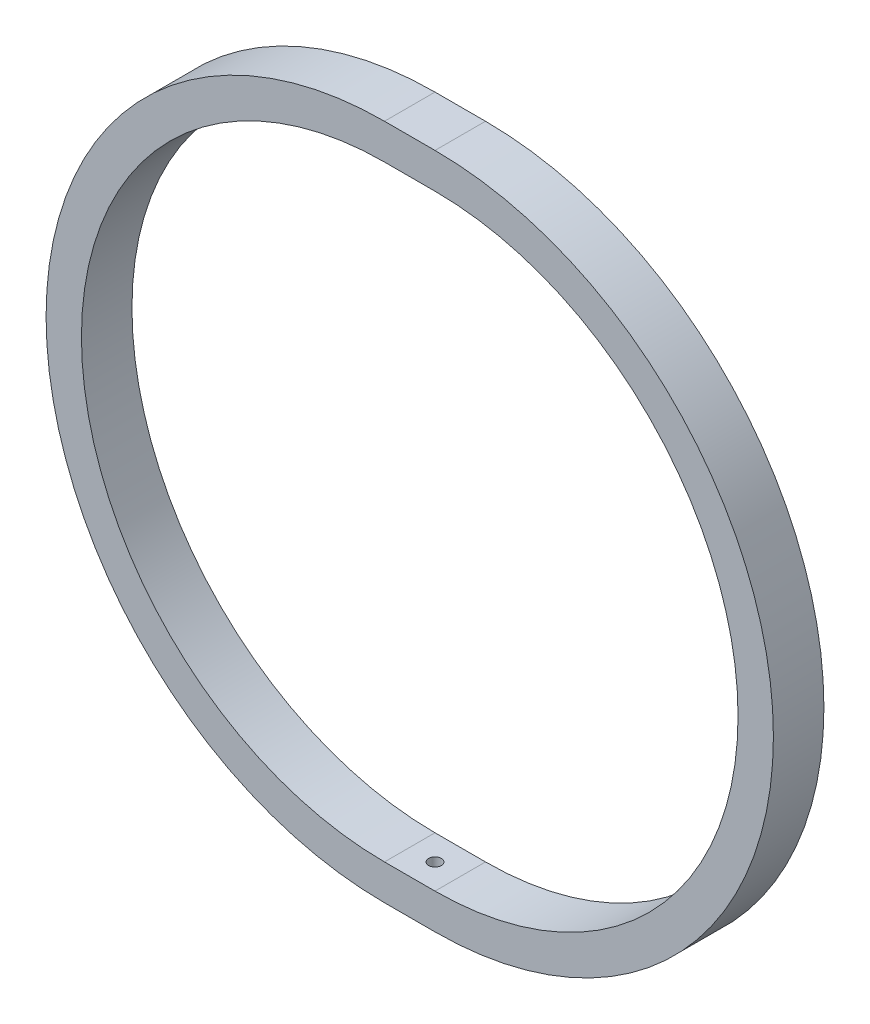
from build123d import *

# Parameters (mm, degrees)
SKETCH1_W           = 10
SKETCH1_H           = 7
REVOLVE1_ANGLE      = 180
SKETCH2_W           = 10
SKETCH2_H           = 7
BOSS_EXTRUDE1_DEPTH = 10
SKETCH4_W           = 10
SKETCH4_H           = 7
REVOLVE3_ANGLE      = 180
SKETCH5_R           = 1.25
CUT_EXTRUDE1_DEPTH  = 2.5


with BuildPart() as part:
    # Sketch1 → Revolve1 (revolve)
    with BuildSketch(Plane(origin=(0, 0, 0), x_dir=(0, 0, -1), z_dir=(1, 0, 0))):
        with Locations((0, 63.5)):
            Rectangle(SKETCH1_W, SKETCH1_H)
    revolve(axis=Axis((0, 0, 29.874383247), (0, 0, 1)), revolution_arc=REVOLVE1_ANGLE)

    # Sketch2 → Boss-Extrude1 (add)
    with BuildSketch(Plane(origin=(0, 0, 0), x_dir=(0, 0, -1), z_dir=(1, 0, 0))):
        with Locations((0, 63.5)):
            Rectangle(SKETCH2_W, SKETCH2_H)
        with Locations((0, -63.5)):
            Rectangle(SKETCH2_W, SKETCH2_H)
    extrude(amount=BOSS_EXTRUDE1_DEPTH)

    # Sketch4 → Revolve3 (revolve)
    with BuildSketch(Plane(origin=(10, 0, 0), x_dir=(0, 0, -1), z_dir=(1, 0, 0))):
        with Locations((0, 63.5)):
            Rectangle(SKETCH4_W, SKETCH4_H)
    revolve(axis=Axis((10, 0, 23.347655249), (0, 0, -1)), revolution_arc=REVOLVE3_ANGLE)

    # Sketch5 → Cut-Extrude1 (cut)
    with BuildSketch(Plane(origin=(0, -60, 0), x_dir=(1, 0, 0), z_dir=(0, 1, 0))):
        with Locations((5, 0)):
            Circle(SKETCH5_R)
    cut_extrude1 = extrude(amount=-CUT_EXTRUDE1_DEPTH, mode=Mode.SUBTRACT)

    # Mirror1: Cut-Extrude1 across plane
    add(cut_extrude1.mirror(Plane.ZX), mode=Mode.SUBTRACT)


solid = part.part
